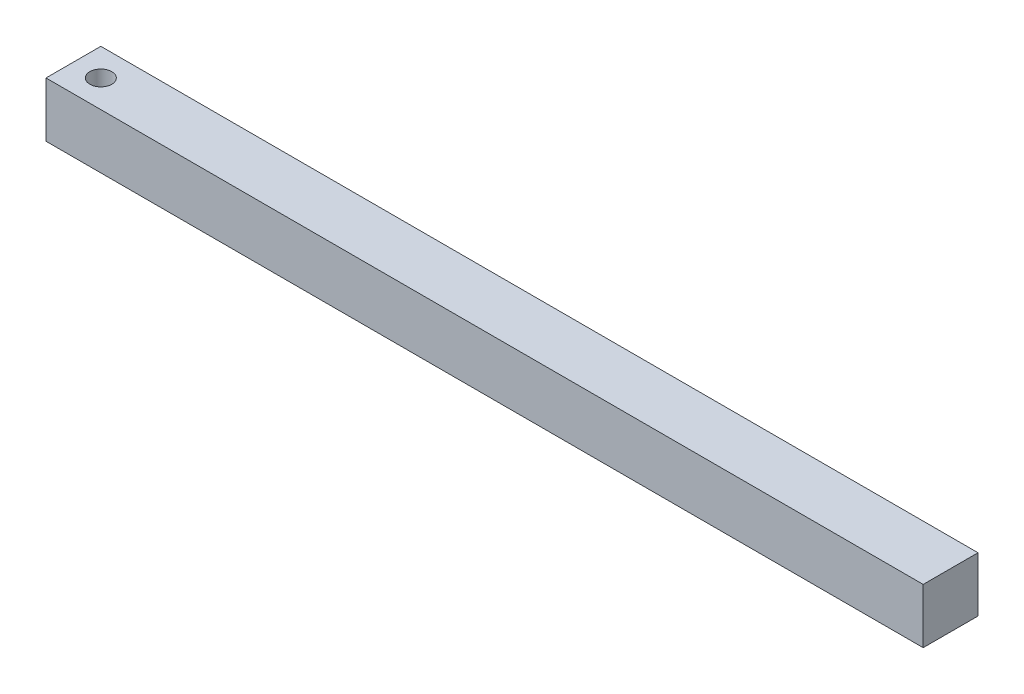
from build123d import *

# Parameters (mm, degrees)
SKETCH1_W           = 152.4
SKETCH1_H           = 9.525
SKETCH1_R           = 1.905
BOSS_EXTRUDE1_DEPTH = 9.525


with BuildPart() as part:
    # Sketch1 → Boss-Extrude1 (new body)
    with BuildSketch(Plane(origin=(0, 0, 0), x_dir=(1, 0, 0), z_dir=(0, 1, 0))):
        with Locations((71.4375, 0)):
            Rectangle(SKETCH1_W, SKETCH1_H)
        Circle(SKETCH1_R, mode=Mode.SUBTRACT)
    extrude(amount=BOSS_EXTRUDE1_DEPTH)


solid = part.part
